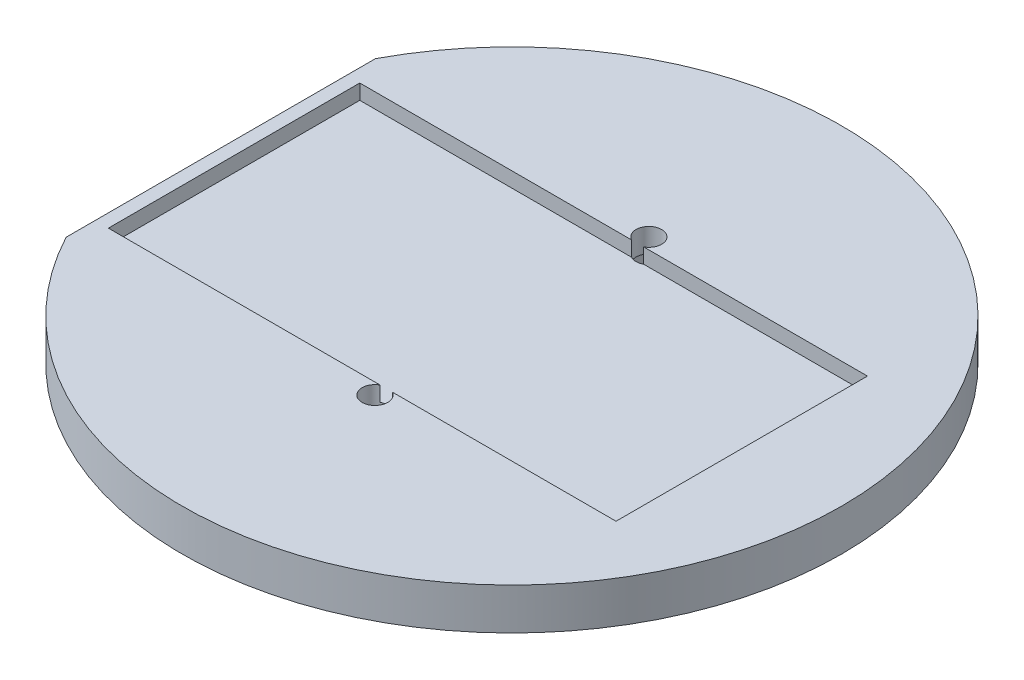
from build123d import *

# Parameters (mm, degrees)
BOSS_EXTRUDE1_DEPTH = 3
SKETCH2_W           = 57.45
SKETCH2_H           = 28.45
BOSS_EXTRUDE2_DEPTH = 1.7
SKETCH3_R           = 1.45
CUT_EXTRUDE1_DEPTH  = 5.7
CUT_EXTRUDE2_DEPTH  = 2


with BuildPart() as part:
    # Sketch1 → Boss-Extrude1 (new body)
    with BuildSketch(Plane(origin=(0, 0, 0), x_dir=(1, 0, 0), z_dir=(0, 1, 0))):
        with BuildLine():
            Line((-32.939945355, 17.5), (-32.939945355, -17.5))
            ThreePointArc((-32.939945355, -17.5), (37.3, 0), (-32.939945355, 17.5))
        make_face()
    extrude(amount=BOSS_EXTRUDE1_DEPTH)

    # Sketch2 → Boss-Extrude2 (add)
    with BuildSketch(Plane(origin=(0, 3, 0), x_dir=(1, 0, 0), z_dir=(0, 1, 0))):
        with BuildLine():
            Line((-32.939945355, 17.5), (-32.939945355, -17.5))
            ThreePointArc((-32.939945355, -17.5), (37.3, 0), (-32.939945355, 17.5))
        make_face()
        with Locations((-2.714945355, 0)):
            Rectangle(SKETCH2_W, SKETCH2_H, mode=Mode.SUBTRACT)
    extrude(amount=BOSS_EXTRUDE2_DEPTH)

    # Sketch3 → Cut-Extrude1 (cut, through all)
    with BuildSketch(Plane(origin=(0, 4.7, 0), x_dir=(1, 0, 0), z_dir=(0, 1, 0))):
        with Locations((0, 15.5)):
            Circle(SKETCH3_R)
    cut_extrude1 = extrude(amount=-CUT_EXTRUDE1_DEPTH, mode=Mode.SUBTRACT)

    # Sketch4 → Cut-Extrude2 (cut)
    with BuildSketch(Plane.XZ):
        Polygon((2.886751346, -15.5), (1.443375673, -13), (-1.443375673, -13), (-2.886751346, -15.5), (-1.443375673, -18), (1.443375673, -18), align=None)
    cut_extrude2 = extrude(amount=-CUT_EXTRUDE2_DEPTH, mode=Mode.SUBTRACT)

    # Mirror2: Cut-Extrude1, Cut-Extrude2 across plane
    add(cut_extrude1.mirror(Plane.XY), mode=Mode.SUBTRACT)
    add(cut_extrude2.mirror(Plane.XY), mode=Mode.SUBTRACT)


solid = part.part
